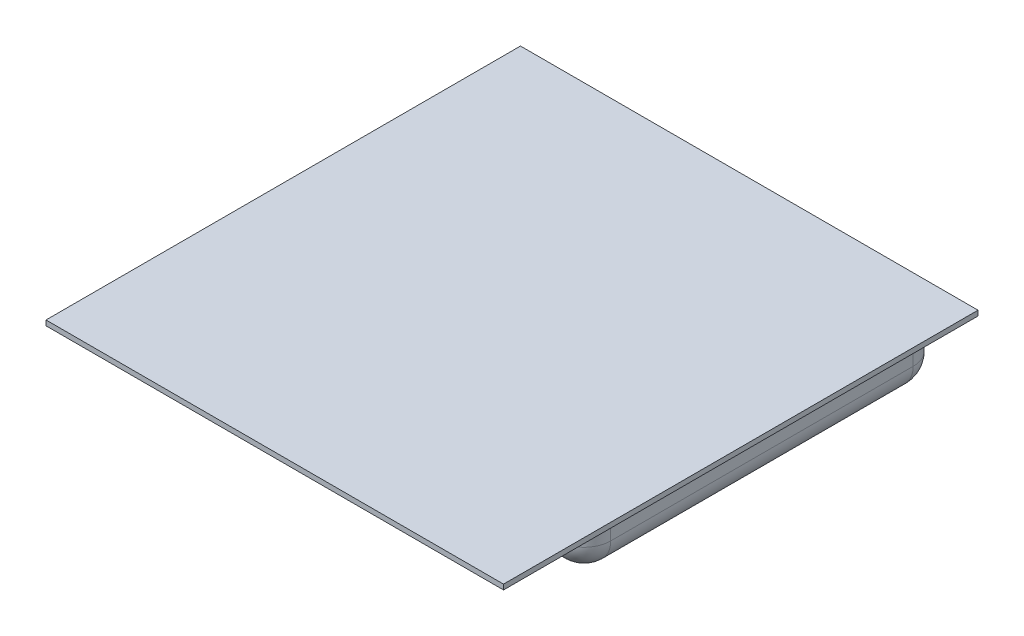
from build123d import *

# Parameters (mm, degrees)
SKETCH1_W      = 171.45
SKETCH1_H      = 1.905
EXTRUDE1_DEPTH = 88.9
SKETCH2_W      = 155.575
SKETCH2_H      = 133.35
EXTRUDE2_DEPTH = 22.1
FILLET1_R      = 10
FILLET2_R      = 10


with BuildPart() as part:
    # Sketch1 → Extrude1 (new body, symmetric)
    with BuildSketch(Plane.XY):
        with Locations((0, 0.9525)):
            Rectangle(SKETCH1_W, SKETCH1_H)
    extrude(amount=EXTRUDE1_DEPTH, both=True)

    # Sketch2 → Extrude2 (add)
    with BuildSketch(Plane.XZ):
        with Locations((0, -15.875)):
            Rectangle(SKETCH2_W, SKETCH2_H)
    extrude(amount=EXTRUDE2_DEPTH)

    # Fillet1
    fillet1_edges = [part.edges().sort_by_distance(p)[0] for p in [
        (-77.7875, -11.05, 50.8),
        (-77.7875, -11.05, -82.55),
        (77.7875, -11.05, -82.55),
        (77.7875, -11.05, 50.8),
    ]]
    fillet(fillet1_edges, radius=FILLET1_R)

    # Fillet2
    fillet2_edges = [part.edges().sort_by_distance(p)[0] for p in [
        (0, -22.1, -82.55),
        (-77.7875, -22.1, -15.875),
        (77.7875, -22.1, -15.875),
        (0, -22.1, 50.8),
        (-74.858567812, -22.1, 47.871067812),
        (74.858567812, -22.1, 47.871067812),
        (74.858567812, -22.1, -79.621067812),
        (-74.858567812, -22.1, -79.621067812),
    ]]
    fillet(fillet2_edges, radius=FILLET2_R)


solid = part.part
